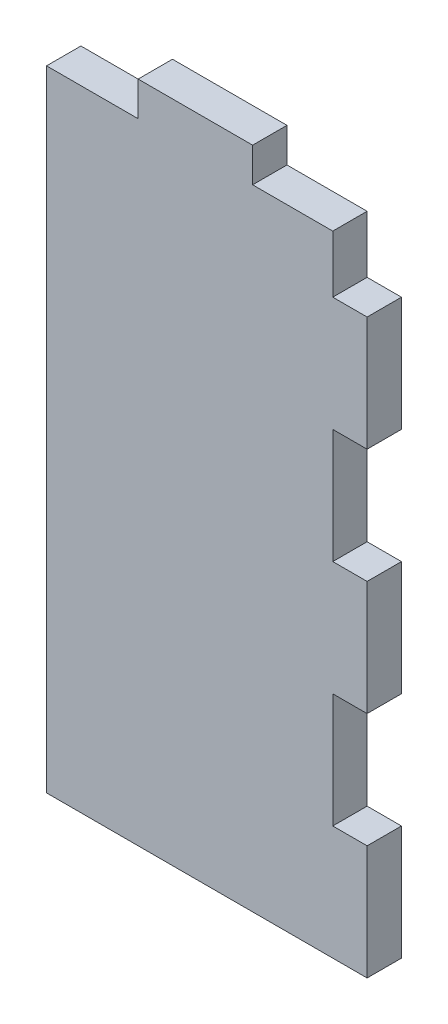
from build123d import *

# Parameters (mm, degrees)
ESQUISSE1_W                = 28
ESQUISSE1_H                = 58
BOSS_EXTRU_1_DEPTH         = 3
ESQUISSE2_W                = 10
ESQUISSE2_H                = 3
ENL_V_MAT_EXTRU_1_DEPTH    = 3
R_P_TITION_LIN_AIRE1_COUNT = 2
R_P_TITION_LIN_AIRE1_PITCH = 20
ESQUISSE3_W                = 3
ESQUISSE3_H                = 10
ENL_V_MAT_EXTRU_2_DEPTH    = 3
R_P_TITION_LIN_AIRE2_COUNT = 3
R_P_TITION_LIN_AIRE2_PITCH = 20


with BuildPart() as part:
    # Esquisse1 → Boss.-Extru.1 (new body)
    with BuildSketch(Plane.XY):
        with Locations((14, -29)):
            Rectangle(ESQUISSE1_W, ESQUISSE1_H)
    extrude(amount=BOSS_EXTRU_1_DEPTH)

    # Esquisse2 → Enlèv. mat.-Extru.1 (cut)
    with BuildSketch(Plane.XY.offset(3)):
        with Locations((23, -1.5)):
            Rectangle(ESQUISSE2_W, ESQUISSE2_H)
    enl_v_mat_extru_1 = extrude(amount=-ENL_V_MAT_EXTRU_1_DEPTH, mode=Mode.SUBTRACT)

    # Répétition linéaire1: Enlèv. mat.-Extru.1 ×2
    with Locations(*[(-i * R_P_TITION_LIN_AIRE1_PITCH, 0, 0) for i in range(1, R_P_TITION_LIN_AIRE1_COUNT)]):
        add(enl_v_mat_extru_1, mode=Mode.SUBTRACT)

    # Esquisse3 → Enlèv. mat.-Extru.2 (cut)
    with BuildSketch(Plane.XY.offset(3)):
        with Locations((26.5, -43)):
            Rectangle(ESQUISSE3_W, ESQUISSE3_H)
    enl_v_mat_extru_2 = extrude(amount=-ENL_V_MAT_EXTRU_2_DEPTH, mode=Mode.SUBTRACT)

    # Répétition linéaire2: Enlèv. mat.-Extru.2 ×3
    with Locations(*[(0, i * R_P_TITION_LIN_AIRE2_PITCH, 0) for i in range(1, R_P_TITION_LIN_AIRE2_COUNT)]):
        add(enl_v_mat_extru_2, mode=Mode.SUBTRACT)


solid = part.part
